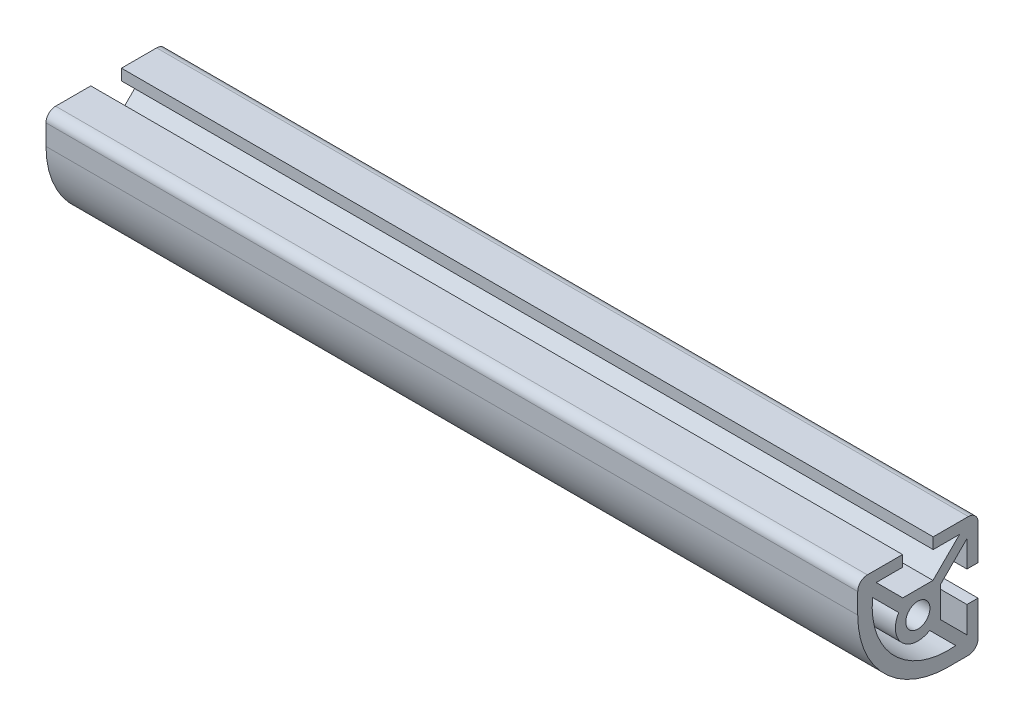
from build123d import *

# Parameters (mm, degrees)
SKETCH3_R                = 2.5527
BOSS_EXTRUDE1_DEPTH      = 85.725
BOSS_EXTRUDE1_DEPTH_BACK = 85.725


with BuildPart() as part:
    # Sketch3 → Boss-Extrude1 (new body, two sides)
    with BuildSketch(Plane(origin=(0, 0, 0), x_dir=(0, 0, -1), z_dir=(1, 0, 0))) as boss_extrude1_sk:
        with BuildLine():
            Line((-10.668, 12.7), (-3.2385, 12.7))
            Line((-3.2385, 12.7), (-3.2385, 10.3632))
            Line((-3.2385, 10.3632), (-8.800635435, 10.3632))
            Line((-8.800635435, 10.3632), (-3.187235669, 4.749800235))
            Line((-3.187235669, 4.749800235), (3.187235669, 4.749800235))
            Line((3.187235669, 4.749800235), (8.800635435, 10.3632))
            Line((8.800635435, 10.3632), (3.2385, 10.3632))
            Line((3.2385, 10.3632), (3.2385, 12.7))
            Line((3.2385, 12.7), (10.668, 12.7))
            ThreePointArc((10.668, 12.7), (12.104840979, 12.104840979), (12.7, 10.668))
            Line((12.7, 10.668), (12.7, 3.2385))
            Line((12.7, 3.2385), (10.3632, 3.2385))
            Line((10.3632, 3.2385), (10.3632, 8.800635435))
            Line((10.3632, 8.800635435), (4.749800235, 3.187235669))
            Line((4.749800235, 3.187235669), (4.749800235, -3.187235669))
            Line((4.749800235, -3.187235669), (10.3632, -8.800635435))
            Line((10.3632, -8.800635435), (10.3632, -3.2385))
            Line((10.3632, -3.2385), (12.7, -3.2385))
            Line((12.7, -3.2385), (12.7, -10.668))
            ThreePointArc((12.7, -10.668), (12.104840979, -12.104840979), (10.668, -12.7))
            Line((10.668, -12.7), (6.35, -12.7))
            ThreePointArc((6.35, -12.7), (-7.120384182, -7.120384182), (-12.7, 6.35))
            Line((-12.7, 6.35), (-12.7, 10.668))
            ThreePointArc((-12.7, 10.668), (-12.104840979, 12.104840979), (-10.668, 12.7))
        make_face()
        Circle(SKETCH3_R, mode=Mode.SUBTRACT)
        with BuildLine():
            Line((2.485198871, -4.047763436), (8.003751298, -9.566315863))
            ThreePointArc((8.003751298, -9.566315863), (-4.965122713, -4.965122713), (-9.566315863, 8.003751298))
            Line((-9.566315863, 8.003751298), (-4.047763436, 2.485198871))
            ThreePointArc((-4.047763436, 2.485198871), (-3.358615955, -3.358615955), (2.485198871, -4.047763436))
        make_face(mode=Mode.SUBTRACT)
    extrude(amount=BOSS_EXTRUDE1_DEPTH)
    extrude(boss_extrude1_sk.sketch, amount=-BOSS_EXTRUDE1_DEPTH_BACK)


solid = part.part
